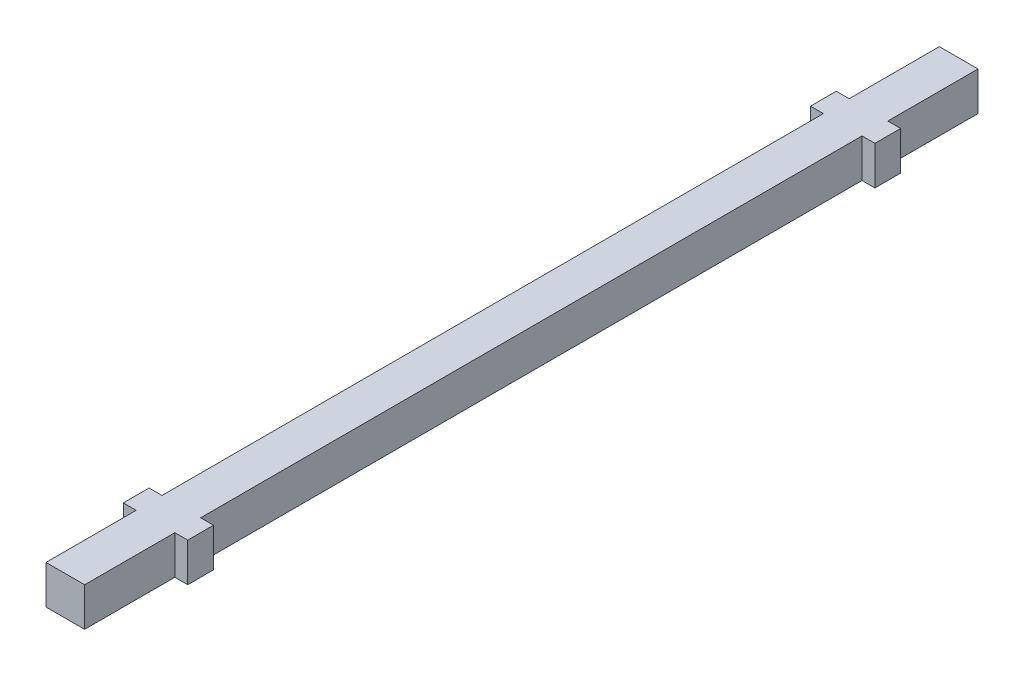
from build123d import *

# Parameters (mm, degrees)
SKETCH1_W           = 9
SKETCH1_H           = 9
BOSS_EXTRUDE1_DEPTH = 104
SKETCH2_W           = 3
SKETCH2_H           = 6
BOSS_EXTRUDE2_DEPTH = 4.5


with BuildPart() as part:
    # Sketch1 → Boss-Extrude1 (new body, symmetric)
    with BuildSketch(Plane.XY):
        Rectangle(SKETCH1_W, SKETCH1_H)
    extrude(amount=BOSS_EXTRUDE1_DEPTH, both=True)

    # Sketch2 → Boss-Extrude2 (add, symmetric)
    with BuildSketch(Plane(origin=(0, 0, 0), x_dir=(1, 0, 0), z_dir=(0, 1, 0))):
        with Locations((-6, -80)):
            Rectangle(SKETCH2_W, SKETCH2_H)
        with Locations((6, -80)):
            Rectangle(SKETCH2_W, SKETCH2_H)
        with Locations((6, 80)):
            Rectangle(SKETCH2_W, SKETCH2_H)
        with Locations((-6, 80)):
            Rectangle(SKETCH2_W, SKETCH2_H)
    extrude(amount=BOSS_EXTRUDE2_DEPTH, both=True)


solid = part.part
